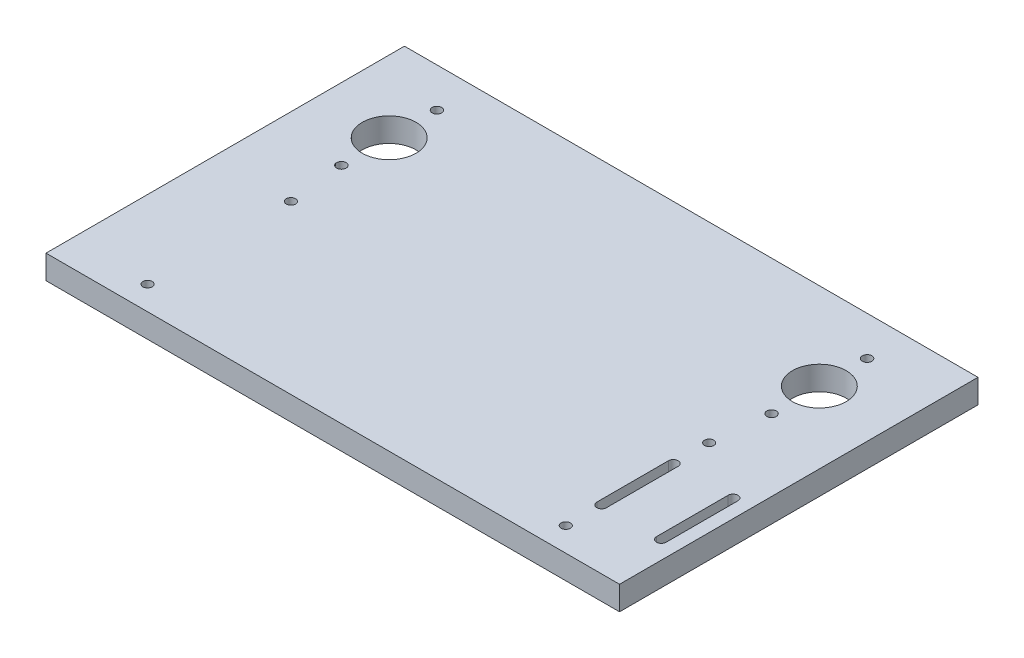
from build123d import *

# Parameters (mm, degrees)
SKETCH1_R           = 2.54
SKETCH1_R_2         = 14.2748
BOSS_EXTRUDE1_DEPTH = 12.7
CUT_EXTRUDE2_DEPTH  = 13.7
SKETCH3_R           = 2.4765
CUT_EXTRUDE3_DEPTH  = 13.7


with BuildPart() as part:
    # Sketch1 → Boss-Extrude1 (new body)
    with BuildSketch(Plane(origin=(0, 0, 0), x_dir=(1, 0, 0), z_dir=(0, 1, 0))):
        Polygon((152.4, 133.35), (-152.4, 133.35), (-152.4, -57.15), (-88.9, -57.15), (88.9, -57.15), (152.4, -57.15), align=None)
        with Locations((-114.3, 61.722)):
            Circle(SKETCH1_R, mode=Mode.SUBTRACT)
        with Locations((-114.3, 87.122)):
            Circle(SKETCH1_R_2, mode=Mode.SUBTRACT)
        with Locations((-114.3, 112.522)):
            Circle(SKETCH1_R, mode=Mode.SUBTRACT)
        with Locations((114.3, 61.722)):
            Circle(SKETCH1_R, mode=Mode.SUBTRACT)
        with Locations((114.3, 87.122)):
            Circle(SKETCH1_R_2, mode=Mode.SUBTRACT)
        with Locations((114.3, 112.522)):
            Circle(SKETCH1_R, mode=Mode.SUBTRACT)
    extrude(amount=BOSS_EXTRUDE1_DEPTH)

    # Sketch2 → Cut-Extrude2 (cut, through all)
    with BuildSketch(Plane(origin=(0, 12.7, 0), x_dir=(1, 0, 0), z_dir=(0, 1, 0))):
        with BuildLine():
            Line((108.5453125, -25.4), (108.5453125, 12.7))
            ThreePointArc((108.5453125, 12.7), (111.125, 15.2796875), (113.7046875, 12.7))
            Line((113.7046875, 12.7), (113.7046875, -25.4))
            ThreePointArc((113.7046875, -25.4), (111.125, -27.9796875), (108.5453125, -25.4))
        make_face()
        with BuildLine():
            Line((140.2953125, -25.4), (140.2953125, 12.7))
            ThreePointArc((140.2953125, 12.7), (142.875, 15.2796875), (145.4546875, 12.7))
            Line((145.4546875, 12.7), (145.4546875, -25.4))
            ThreePointArc((145.4546875, -25.4), (142.875, -27.9796875), (140.2953125, -25.4))
        make_face()
    extrude(amount=-CUT_EXTRUDE2_DEPTH, mode=Mode.SUBTRACT)

    # Sketch3 → Cut-Extrude3 (cut, through all)
    with BuildSketch(Plane(origin=(0, 0, 0), x_dir=(-1, 0, 0), z_dir=(0, -1, 0))):
        with Locations((-111.125, -44.45)):
            Circle(SKETCH3_R)
        with Locations((-111.125, 31.75)):
            Circle(SKETCH3_R)
        with Locations((111.125, 31.75)):
            Circle(SKETCH3_R)
        with Locations((111.125, -44.45)):
            Circle(SKETCH3_R)
    extrude(amount=-CUT_EXTRUDE3_DEPTH, mode=Mode.SUBTRACT)


solid = part.part
